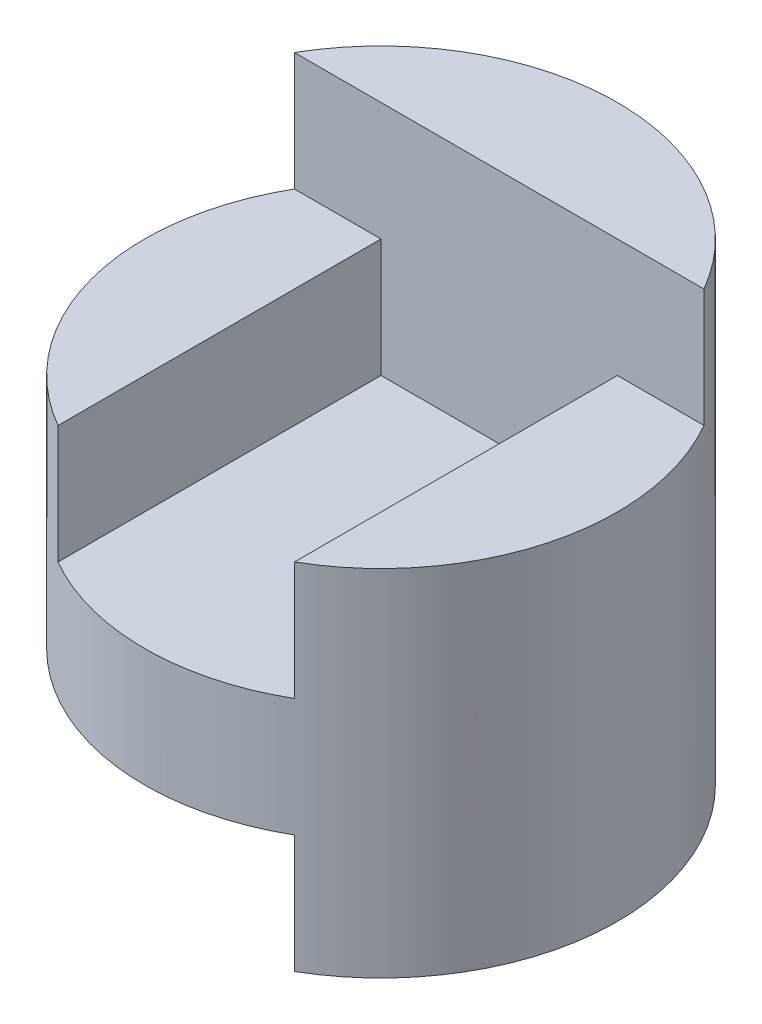
from build123d import *

# Parameters (mm, degrees)
SKETCH1_R               = 2
BOSS_EXTRUDE1_DEPTH     = 4
CUT_EXTRUDE1_DEPTH      = 3
CUT_EXTRUDE1_DEPTH_BACK = 1
CUT_EXTRUDE9_DEPTH      = 1


with BuildPart() as part:
    # Sketch1 → Boss-Extrude1 (new body)
    with BuildSketch(Plane(origin=(0, 0, 0), x_dir=(1, 0, 0), z_dir=(0, 1, 0))):
        Circle(SKETCH1_R)
    extrude(amount=BOSS_EXTRUDE1_DEPTH)

    # Sketch2 → Cut-Extrude1 (cut, two sides)
    with BuildSketch(Plane.XY) as cut_extrude1_sk:
        Polygon((-2, 4), (2, 4), (2, 3), (1, 3), (1, 2), (-1, 2), (-1, 3), (-2, 3), align=None)
    extrude(amount=CUT_EXTRUDE1_DEPTH, mode=Mode.SUBTRACT)
    extrude(cut_extrude1_sk.sketch, amount=-CUT_EXTRUDE1_DEPTH_BACK, mode=Mode.SUBTRACT)

    # Sketch4 → Cut-Extrude9 (cut)
    with BuildSketch(Plane.XZ):
        with BuildLine():
            Line((-1, -1), (-1.732050808, -1))
            ThreePointArc((-1.732050808, -1), (-1.414213562, 1.414213562), (1, 1.732050808))
            Line((1, 1.732050808), (1, -1))
            Line((1, -1), (-1, -1))
        make_face()
    extrude(amount=-CUT_EXTRUDE9_DEPTH, mode=Mode.SUBTRACT)


solid = part.part
